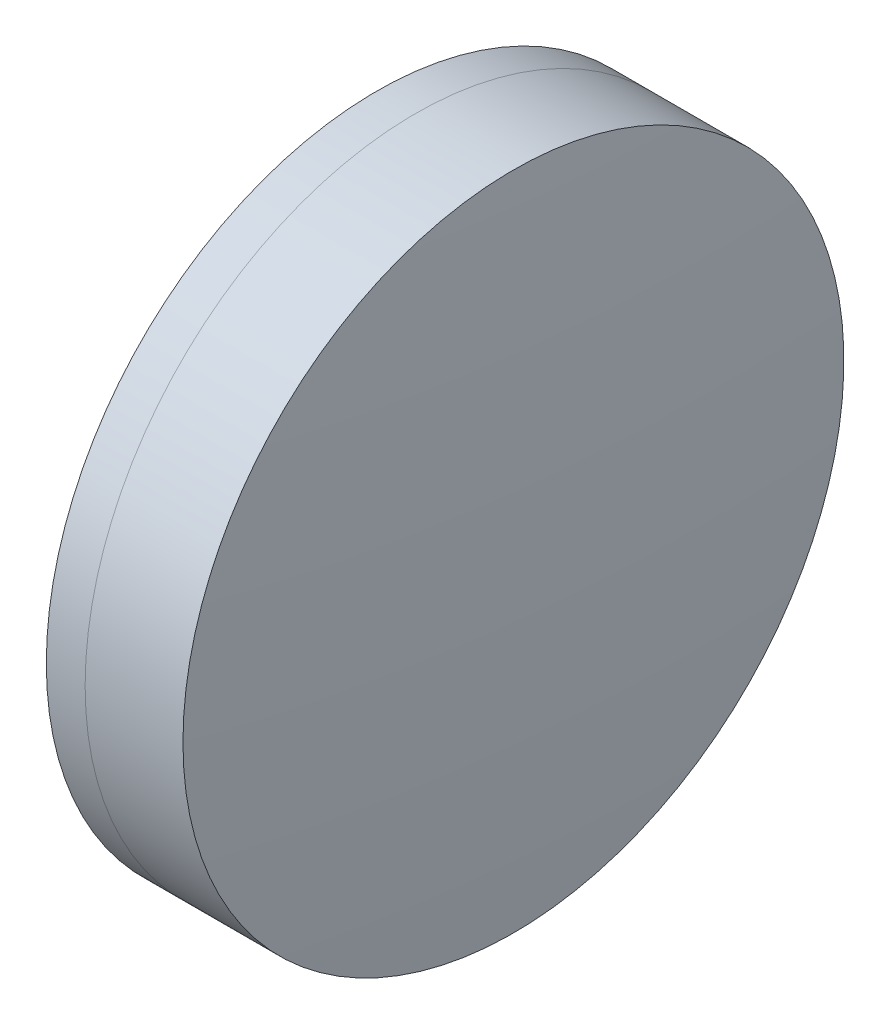
from build123d import *


with BuildPart() as part:
    # 草图1 one side → 旋转1 (revolve)
    with BuildSketch(Plane(origin=(0, 0, 0), x_dir=(1, 0, 0), z_dir=(0, 1, 0)), mode=Mode.PRIVATE) as revolve_1_sk:
        with BuildLine():
            ThreePointArc((264.042139171, 12.7), (263.257861496, 6.371513356), (262.995845808, 0))
            Line((262.995845808, 0), (266.995845808, 0))
            ThreePointArc((266.995845808, 0), (266.62919886, 6.391924501), (265.534067675, 12.7))
            Line((265.534067675, 12.7), (264.042139171, 12.7))
        make_face()
    revolve(revolve_1_sk.sketch.rotate(Axis((235.807450691, 0, 0), (1, 0, 0)), 180), axis=Axis((235.807450691, 0, 0), (1, 0, 0)))  # turned: the seam where the file's is


with BuildPart() as body_2:
    # 草图2 one side → 旋转3 (revolve)
    with BuildSketch(Plane(origin=(0, 0, 0), x_dir=(1, 0, 0), z_dir=(0, 1, 0)), mode=Mode.PRIVATE) as revolve_3_sk:
        with BuildLine():
            Line((269.29353762, 12.7), (265.534067675, 12.7))
            ThreePointArc((265.534067675, 12.7), (266.62919886, 6.391924501), (266.995845808, 0))
            Line((266.995845808, 0), (269.795845808, 0))
            ThreePointArc((269.795845808, 0), (269.670219688, 6.354964861), (269.29353762, 12.7))
        make_face()
    revolve(revolve_3_sk.sketch.rotate(Axis((-0.551919993, 0, 0), (1, 0, 0)), 180), axis=Axis((-0.551919993, 0, 0), (1, 0, 0)))  # turned: the seam where the file's is


solid = Compound([part.part, body_2.part])
